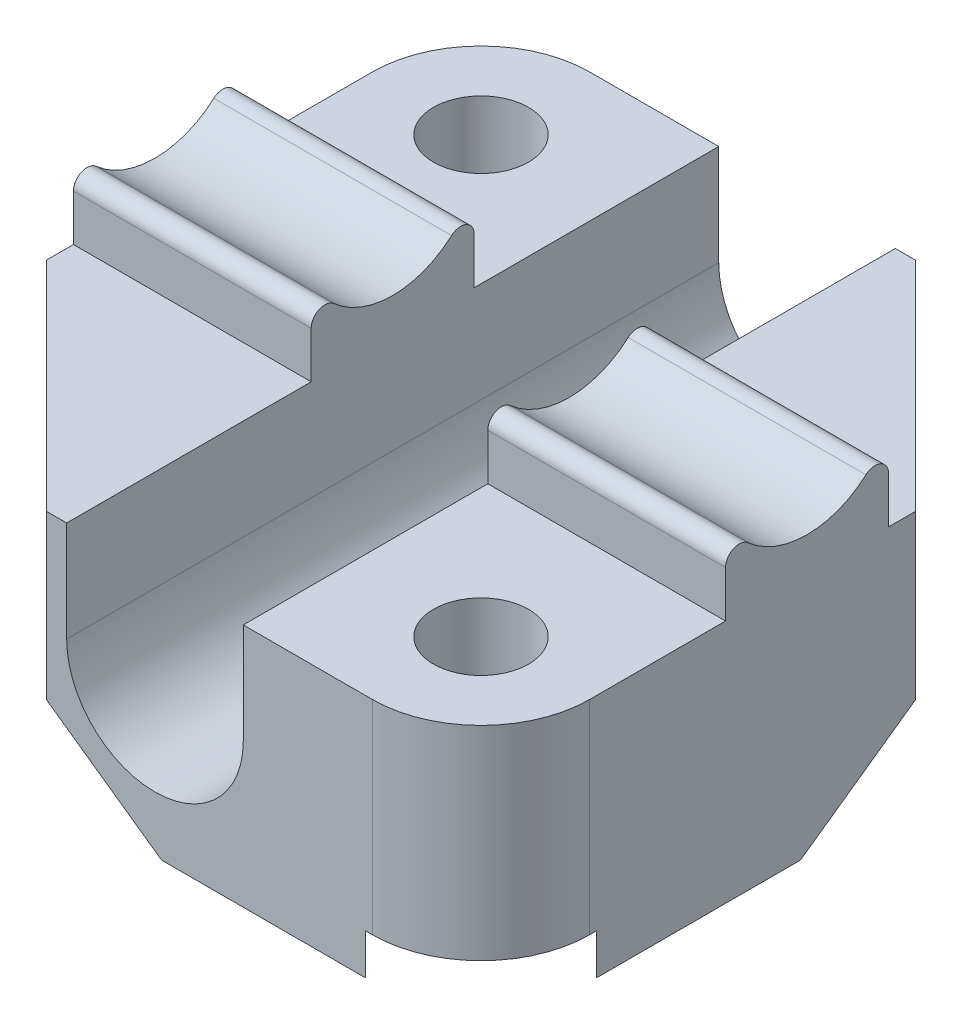
from build123d import *

# Parameters (mm, degrees)
SKETCH_1_W               = 24
SKETCH_1_H               = 24
EXTRUDE_1_DEPTH          = 10
CUT_EXTRUDE_1_DEPTH      = 29.635642127
CUT_EXTRUDE_1_DEPTH_BACK = 29.635642127
EXTRUDE_2_DEPTH          = 8.75
SKETCH_5_R               = 1.75
CUT_EXTRUDE_3_DEPTH      = 20.697715604
CHAMFER_1_SIZE           = 8
FILLET_1_R               = 4
FILLET_2_R               = 0.5
CHAMFER_2_SIZE           = 4
SKETCH_6_R               = 1.75
CUT_EXTRUDE_4_DEPTH      = 2.5
CHAMFER_3_SIZE           = 1


with BuildPart() as part:
    # 草图1 → 凸台-拉伸1 (new body)
    with BuildSketch(Plane(origin=(0, 0, 0), x_dir=(1, 0, 0), z_dir=(0, 1, 0))):
        Rectangle(SKETCH_1_W, SKETCH_1_H)
    extrude(amount=EXTRUDE_1_DEPTH)

    # 草图2 → 切除-拉伸1 (cut, two sides)
    with BuildSketch(Plane.XY.offset(12)) as cut_extrude_1_sk:
        with BuildLine():
            Line((-3.25, 10), (-3.25, 6.3))
            ThreePointArc((-3.25, 6.3), (-2.298097039, 8.598097039), (0, 9.55))
            Line((0, 9.55), (0, 10))
            Line((0, 10), (-3.25, 10))
        make_face()
        with BuildLine():
            ThreePointArc((0, 9.55), (2.298097039, 8.598097039), (3.25, 6.3))
            Line((3.25, 6.3), (3.25, 10))
            Line((3.25, 10), (0, 10))
            Line((0, 10), (0, 9.55))
        make_face()
        with BuildLine():
            ThreePointArc((-3.25, 6.3), (-2.298097039, 4.001902961), (0, 3.05))
            Line((0, 3.05), (0, 6.3))
            Line((0, 6.3), (-3.25, 6.3))
        make_face()
        with BuildLine():
            Line((0, 6.3), (0, 3.05))
            ThreePointArc((0, 3.05), (2.298097039, 4.001902961), (3.25, 6.3))
            Line((3.25, 6.3), (0, 6.3))
        make_face()
        with BuildLine():
            Line((-3.25, 6.3), (0, 6.3))
            Line((0, 6.3), (0, 9.55))
            ThreePointArc((0, 9.55), (-2.298097039, 8.598097039), (-3.25, 6.3))
        make_face()
        with BuildLine():
            Line((0, 9.55), (0, 6.3))
            Line((0, 6.3), (3.25, 6.3))
            ThreePointArc((3.25, 6.3), (2.298097039, 8.598097039), (0, 9.55))
        make_face()
    extrude(amount=CUT_EXTRUDE_1_DEPTH, mode=Mode.SUBTRACT)
    extrude(cut_extrude_1_sk.sketch, amount=-CUT_EXTRUDE_1_DEPTH_BACK, mode=Mode.SUBTRACT)

    # 草图4 → 凸台-拉伸2 (add)
    with BuildSketch(Plane(origin=(12, 0, 0), x_dir=(0, 0, -1), z_dir=(1, 0, 0))):
        with BuildLine():
            Line((-3, 10), (3, 10))
            Line((3, 10), (3, 13.25))
            ThreePointArc((3, 13.25), (0, 11.25), (-3, 13.25))
            Line((-3, 13.25), (-3, 10))
        make_face()
    extrude_2 = extrude(amount=-EXTRUDE_2_DEPTH)

    # 镜向2: 凸台-拉伸2 across plane
    add(extrude_2.mirror(Plane(origin=(0, 0, 0), x_dir=(0, 0, 1), z_dir=(1, 0, 0))))

    # 草图5 → 切除-拉伸3 (cut, through all)
    with BuildSketch(Plane(origin=(0, 10, 0), x_dir=(1, 0, 0), z_dir=(0, 1, 0))):
        with Locations(Location((-8, 8, 0), (0, 0, 270))):
            Circle(SKETCH_5_R)
        with Locations(Location((8, -8, 0), (0, 0, 90))):
            Circle(SKETCH_5_R)
    extrude(amount=-CUT_EXTRUDE_3_DEPTH, mode=Mode.SUBTRACT)

    # 倒角1
    chamfer_1_edges = [part.edges().sort_by_distance(p)[0] for p in [
        (-12, 5, 12),
        (12, 5, -12),
    ]]
    chamfer(chamfer_1_edges, length=CHAMFER_1_SIZE)

    # 圆角1
    fillet_1_edges = [part.edges().sort_by_distance(p)[0] for p in [
        (12, 5, 12),
        (-12, 5, -12),
    ]]
    fillet(fillet_1_edges, radius=FILLET_1_R)

    # 圆角2
    fillet_2_edges = [part.edges().sort_by_distance(p)[0] for p in [
        (7.625, 13.25, 3),
        (7.625, 13.25, -3),
        (-7.625, 13.25, -3),
        (-7.625, 13.25, 3),
    ]]
    fillet(fillet_2_edges, radius=FILLET_2_R)

    # 倒角2
    chamfer_2_edges = [part.edges().sort_by_distance(p)[0] for p in [
        (-8, 0, 8),
        (8, 0, -8),
    ]]
    chamfer(chamfer_2_edges, length=CHAMFER_2_SIZE)

    # 草图6 → 切除-拉伸4 (cut)
    with BuildSketch(Plane.XZ):
        Polygon((-8.896575472, -4.653934785), (-11.346065215, -7.103424528), (-7.103424528, -11.346065215), (-4.653934785, -8.896575472), (-5.550510257, -5.550510257), align=None)
        with Locations(Location((-8, -8, 0), (0, 0, 90))):
            Circle(SKETCH_6_R, mode=Mode.SUBTRACT)
        with BuildLine():
            Line((-12, -8), (-12, -7.757359313))
            Line((-12, -7.757359313), (-18.417133027, -14.17449234))
            Line((-18.417133027, -14.17449234), (-14.17449234, -18.417133027))
            Line((-14.17449234, -18.417133027), (-7.757359313, -12))
            Line((-7.757359313, -12), (-8, -12))
            ThreePointArc((-8, -12), (-10.828427125, -10.828427125), (-12, -8))
        make_face()
        with Locations(Location((-8, -8, 0), (0, 0, 90))):
            Circle(SKETCH_6_R)
        Polygon((-11.346065215, -7.103424528), (-7.103424528, -11.346065215), (-10.449489743, -10.449489743), align=None)
        with BuildLine():
            Line((-10.449489743, -10.449489743), (-11.346065215, -7.103424528))
            Line((-11.346065215, -7.103424528), (-12, -7.757359313))
            Line((-12, -7.757359313), (-12, -8))
            ThreePointArc((-12, -8), (-10.828427125, -10.828427125), (-8, -12))
            Line((-8, -12), (-7.757359313, -12))
            Line((-7.757359313, -12), (-7.103424528, -11.346065215))
            Line((-7.103424528, -11.346065215), (-10.449489743, -10.449489743))
        make_face()
        Polygon((5.550510257, 5.550510257), (4.653934785, 8.896575472), (7.103424528, 11.346065215), (11.346065215, 7.103424528), (8.896575472, 4.653934785), align=None)
        with Locations(Location((8, 8, 0), (0, 0, 270))):
            Circle(SKETCH_6_R, mode=Mode.SUBTRACT)
        with Locations(Location((8, 8, 0), (0, 0, 270))):
            Circle(SKETCH_6_R)
        Polygon((7.103424528, 11.346065215), (10.449489743, 10.449489743), (11.346065215, 7.103424528), align=None)
        with BuildLine():
            Line((8, 12), (7.757359313, 12))
            Line((7.757359313, 12), (7.103424528, 11.346065215))
            Line((7.103424528, 11.346065215), (10.449489743, 10.449489743))
            Line((10.449489743, 10.449489743), (11.346065215, 7.103424528))
            Line((11.346065215, 7.103424528), (12, 7.757359313))
            Line((12, 7.757359313), (12, 8))
            ThreePointArc((12, 8), (10.828427125, 10.828427125), (8, 12))
        make_face()
        with BuildLine():
            Line((18.417133027, 14.17449234), (14.17449234, 18.417133027))
            Line((14.17449234, 18.417133027), (7.757359313, 12))
            Line((7.757359313, 12), (8, 12))
            ThreePointArc((8, 12), (10.828427125, 10.828427125), (12, 8))
            Line((12, 8), (12, 7.757359313))
            Line((12, 7.757359313), (18.417133027, 14.17449234))
        make_face()
    extrude(amount=-CUT_EXTRUDE_4_DEPTH, mode=Mode.SUBTRACT)

    # 倒角3
    chamfer_3_edges = [part.edges().sort_by_distance(p)[0] for p in [
        (4.707106781, 0, 12),
        (-4.707106781, 0, -12),
        (12, 0, 4.707106781),
        (-12, 0, -4.707106781),
    ]]
    chamfer(chamfer_3_edges, length=CHAMFER_3_SIZE)


solid = part.part
